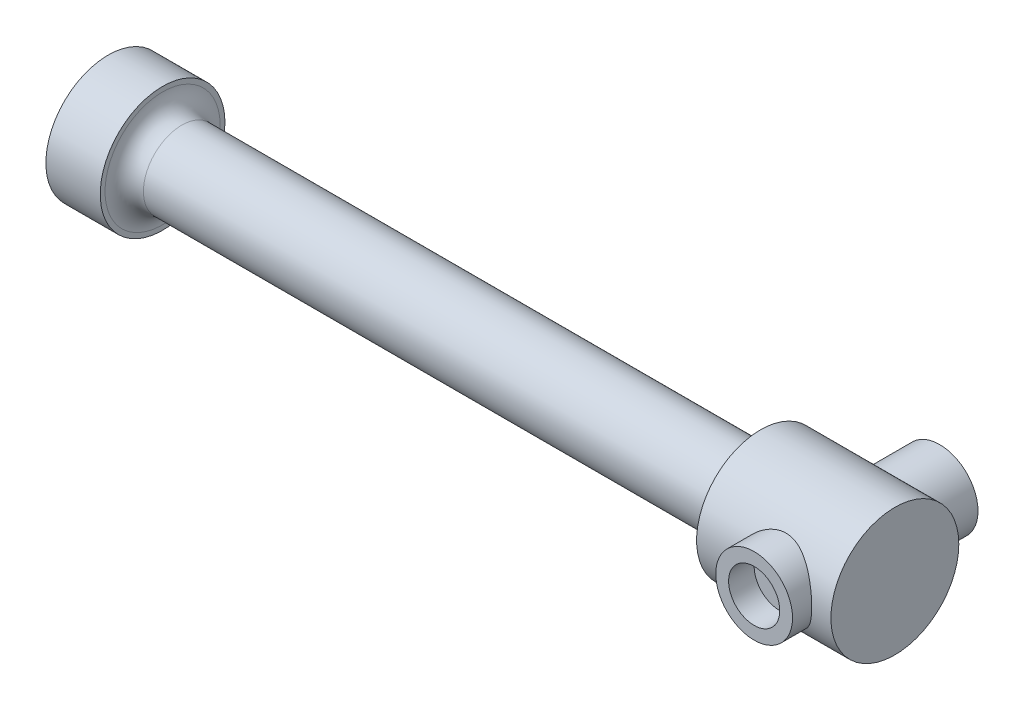
from build123d import *

# Parameters (mm, degrees)
SKETCH2_R                = 9.75
BOSS_EXTRUDE1_DEPTH      = 8.5
SKETCH3_R                = 6
BOSS_EXTRUDE2_DEPTH      = 93.5
FILLET1_R                = 3
SKETCH4_R                = 10
BOSS_EXTRUDE3_DEPTH      = 21
FILLET2_R                = 2
SKETCH5_R                = 6
BOSS_EXTRUDE4_DEPTH      = 13
BOSS_EXTRUDE4_DEPTH_BACK = 16
SKETCH6_R                = 4
CUT_EXTRUDE1_DEPTH       = 4
CUT_EXTRUDE2_REACH       = 27
SKETCH7_R                = 1.5
SKETCH8_R                = 4
CUT_EXTRUDE3_DEPTH       = 4


with BuildPart() as part:
    # Sketch2 → Boss-Extrude1 (new body)
    with BuildSketch(Plane(origin=(0, 0, 0), x_dir=(0, 0, -1), z_dir=(1, 0, 0))):
        Circle(SKETCH2_R)
    extrude(amount=BOSS_EXTRUDE1_DEPTH)

    # Sketch3 → Boss-Extrude2 (add)
    with BuildSketch(Plane(origin=(8.5, 0, 0), x_dir=(0, 0, -1), z_dir=(1, 0, 0))):
        Circle(SKETCH3_R)
    extrude(amount=BOSS_EXTRUDE2_DEPTH)

    # Fillet1
    fillet1_edges = [part.edges().sort_by_distance(p)[0] for p in [
        (8.5, 0, 6),
    ]]
    fillet(fillet1_edges, radius=FILLET1_R)

    # Sketch4 → Boss-Extrude3 (add)
    with BuildSketch(Plane(origin=(102, 0, 0), x_dir=(0, 0, -1), z_dir=(1, 0, 0))):
        Circle(SKETCH4_R)
    extrude(amount=BOSS_EXTRUDE3_DEPTH)

    # Fillet2
    fillet2_edges = [part.edges().sort_by_distance(p)[0] for p in [
        (102, 0, 6),
    ]]
    fillet(fillet2_edges, radius=FILLET2_R)

    # Sketch5 → Boss-Extrude4 (add, two sides)
    with BuildSketch(Plane.XY) as boss_extrude4_sk:
        with Locations((114, 0)):
            Circle(SKETCH5_R)
    extrude(amount=BOSS_EXTRUDE4_DEPTH)
    extrude(boss_extrude4_sk.sketch, amount=-BOSS_EXTRUDE4_DEPTH_BACK)

    # Sketch6 → Cut-Extrude1 (cut)
    with BuildSketch(Plane.XY.offset(13)):
        with Locations((114, 0)):
            Circle(SKETCH6_R)
    extrude(amount=-CUT_EXTRUDE1_DEPTH, mode=Mode.SUBTRACT)

    # Sketch7 → Cut-Extrude2 (cut, up to next)
    with BuildSketch(Plane.XY.offset(9), mode=Mode.PRIVATE) as cut_extrude2_sk1:
        with Locations((114, 0)):
            Circle(SKETCH7_R)
    cut_extrude2_tool1 = extrude(cut_extrude2_sk1.sketch, amount=-CUT_EXTRUDE2_REACH, mode=Mode.PRIVATE) & part.part
    add(cut_extrude2_tool1.solids().sort_by_distance((114, 0, 9))[0], mode=Mode.SUBTRACT)

    # Sketch8 → Cut-Extrude3 (cut)
    with BuildSketch(Plane(origin=(0, 0, -16), x_dir=(-1, 0, 0), z_dir=(0, 0, -1))):
        with Locations((-114, 0)):
            Circle(SKETCH8_R)
    extrude(amount=-CUT_EXTRUDE3_DEPTH, mode=Mode.SUBTRACT)


solid = part.part
